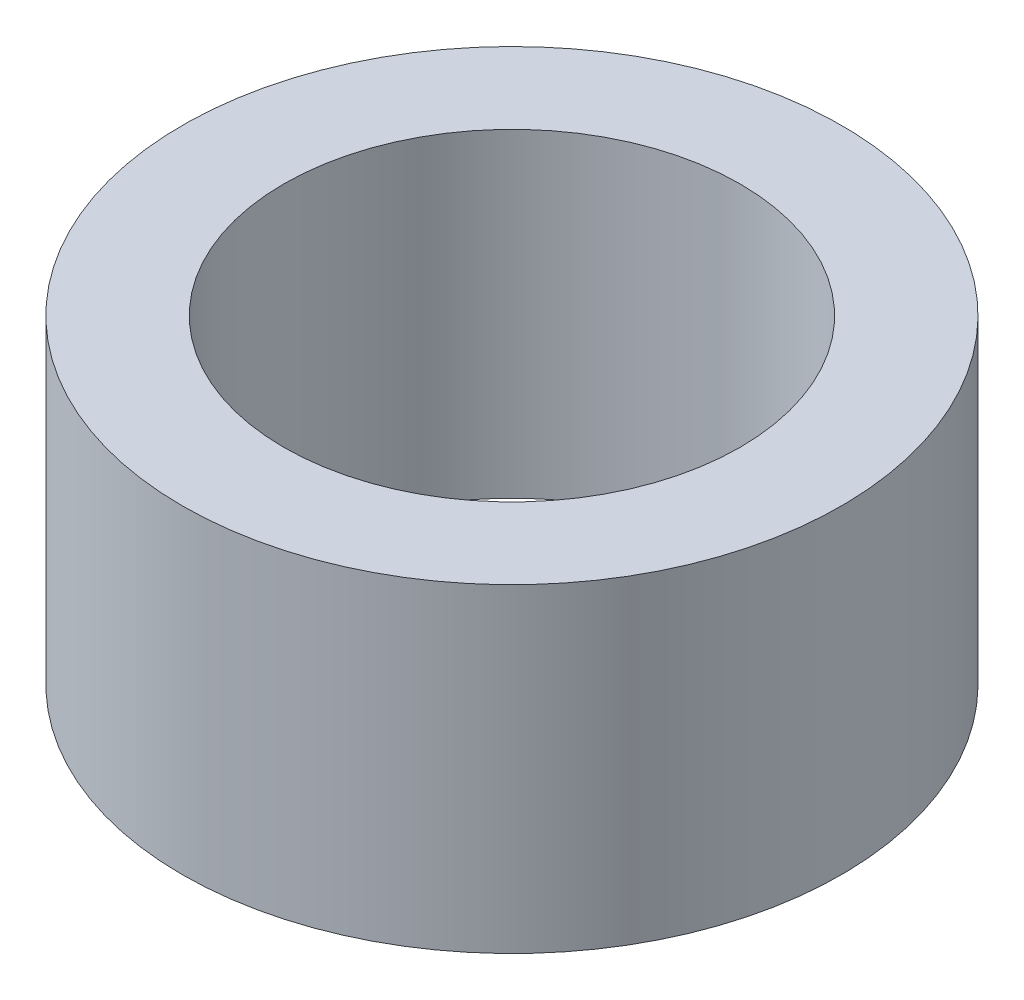
from build123d import *

# Parameters (mm, degrees)
SKETCH1_R           = 13
SKETCH1_R_2         = 9
BOSS_EXTRUDE1_DEPTH = 12.6


with BuildPart() as part:
    # Sketch1 → Boss-Extrude1 (new body)
    with BuildSketch(Plane(origin=(0, 0, 0), x_dir=(1, 0, 0), z_dir=(0, 1, 0))):
        with Locations((-1.526165809, 3.052331618)):
            Circle(SKETCH1_R)
        with Locations((-1.526165809, 3.052331618)):
            Circle(SKETCH1_R_2, mode=Mode.SUBTRACT)
    extrude(amount=BOSS_EXTRUDE1_DEPTH)


solid = part.part
